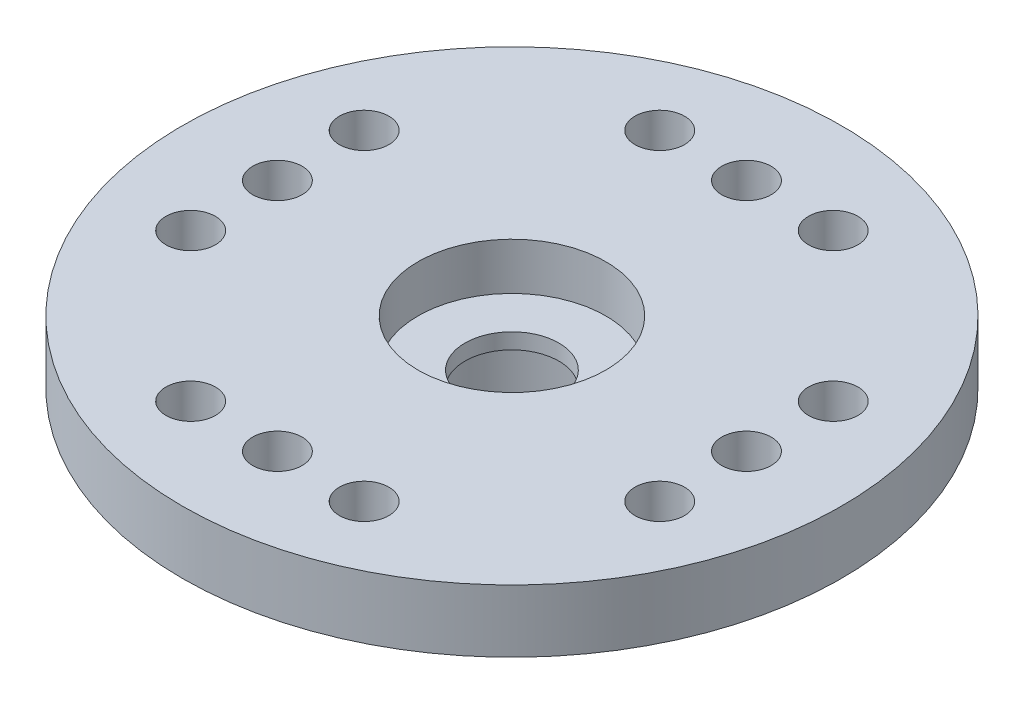
from build123d import *

# Parameters (mm, degrees)
SKETCH_1_R           = 10.525
EXTRUDE_1_DEPTH      = 2
SKETCH_2_R           = 4.1
EXTRUDE_2_DEPTH      = 3.7
SKETCH_3_R           = 2.97
CUT_EXTRUDE_1_DEPTH  = 3.7
SKETCH_4_R           = 1.5
CUT_EXTRUDE_2_DEPTH  = 2
SKETCH_5_R           = 3
CUT_EXTRUDE_3_DEPTH  = 1.5
SKETCH_6_R           = 0.79
CUT_EXTRUDE_4_DEPTH  = 2
SKETCH_7_R           = 0.79
CUT_EXTRUDE_5_DEPTH  = 2
SKETCH_8_R           = 0.79
CUT_EXTRUDE_6_DEPTH  = 2
SKETCH_9_R           = 0.79
CUT_EXTRUDE_7_DEPTH  = 2
SKETCH_10_R          = 0.79
CUT_EXTRUDE_8_DEPTH  = 2
SKETCH_11_R          = 0.79
CUT_EXTRUDE_9_DEPTH  = 2
SKETCH_12_R          = 0.79
CUT_EXTRUDE_10_DEPTH = 2
SKETCH_13_R          = 0.79
CUT_EXTRUDE_11_DEPTH = 2
SKETCH_14_R          = 0.79
CUT_EXTRUDE_12_DEPTH = 2
SKETCH_15_R          = 0.79
CUT_EXTRUDE_13_DEPTH = 2
SKETCH_16_R          = 0.79
CUT_EXTRUDE_14_DEPTH = 2
SKETCH_17_R          = 0.79
CUT_EXTRUDE_15_DEPTH = 2


with BuildPart() as part:
    # ｽｹｯﾁ1 → ﾎﾞｽ - 押し出し1 (new body)
    with BuildSketch(Plane(origin=(0, 0, 0), x_dir=(1, 0, 0), z_dir=(0, 1, 0))):
        Circle(SKETCH_1_R)
    extrude(amount=EXTRUDE_1_DEPTH)

    # ｽｹｯﾁ2 → ﾎﾞｽ - 押し出し2 (add)
    with BuildSketch(Plane(origin=(0, 0, 0), x_dir=(-1, 0, 0), z_dir=(0, -1, 0))):
        Circle(SKETCH_2_R)
    extrude(amount=EXTRUDE_2_DEPTH)

    # ｽｹｯﾁ3 → ｶｯﾄ - 押し出し1 (cut)
    with BuildSketch(Plane(origin=(0, -3.7, 0), x_dir=(-1, 0, 0), z_dir=(0, -1, 0))):
        Circle(SKETCH_3_R)
    extrude(amount=-CUT_EXTRUDE_1_DEPTH, mode=Mode.SUBTRACT)

    # ｽｹｯﾁ4 → ｶｯﾄ - 押し出し2 (cut)
    with BuildSketch(Plane(origin=(0, 2, 0), x_dir=(1, 0, 0), z_dir=(0, 1, 0))):
        Circle(SKETCH_4_R)
    extrude(amount=-CUT_EXTRUDE_2_DEPTH, mode=Mode.SUBTRACT)

    # ｽｹｯﾁ5 → ｶｯﾄ - 押し出し3 (cut)
    with BuildSketch(Plane(origin=(0, 2, 0), x_dir=(1, 0, 0), z_dir=(0, 1, 0))):
        Circle(SKETCH_5_R)
    extrude(amount=-CUT_EXTRUDE_3_DEPTH, mode=Mode.SUBTRACT)

    # ｽｹｯﾁ6 → ｶｯﾄ - 押し出し4 (cut)
    with BuildSketch(Plane(origin=(0, 2, 0), x_dir=(1, 0, 0), z_dir=(0, 1, 0))):
        with Locations((0, 7.49)):
            Circle(SKETCH_6_R)
    extrude(amount=-CUT_EXTRUDE_4_DEPTH, mode=Mode.SUBTRACT)

    # ｽｹｯﾁ7 → ｶｯﾄ - 押し出し5 (cut)
    with BuildSketch(Plane(origin=(0, 2, 0), x_dir=(1, 0, 0), z_dir=(0, 1, 0))):
        with Locations((2.77, 7.49)):
            Circle(SKETCH_7_R)
    extrude(amount=-CUT_EXTRUDE_5_DEPTH, mode=Mode.SUBTRACT)

    # ｽｹｯﾁ8 → ｶｯﾄ - 押し出し6 (cut)
    with BuildSketch(Plane(origin=(0, 2, 0), x_dir=(1, 0, 0), z_dir=(0, 1, 0))):
        with Locations((-2.77, 7.49)):
            Circle(SKETCH_8_R)
    extrude(amount=-CUT_EXTRUDE_6_DEPTH, mode=Mode.SUBTRACT)

    # ｽｹｯﾁ9 → ｶｯﾄ - 押し出し7 (cut)
    with BuildSketch(Plane(origin=(0, 2, 0), x_dir=(1, 0, 0), z_dir=(0, 1, 0))):
        with Locations((7.49, 0)):
            Circle(SKETCH_9_R)
    extrude(amount=-CUT_EXTRUDE_7_DEPTH, mode=Mode.SUBTRACT)

    # ｽｹｯﾁ10 → ｶｯﾄ - 押し出し8 (cut)
    with BuildSketch(Plane(origin=(0, 2, 0), x_dir=(1, 0, 0), z_dir=(0, 1, 0))):
        with Locations((7.49, -2.77)):
            Circle(SKETCH_10_R)
    extrude(amount=-CUT_EXTRUDE_8_DEPTH, mode=Mode.SUBTRACT)

    # ｽｹｯﾁ11 → ｶｯﾄ - 押し出し9 (cut)
    with BuildSketch(Plane(origin=(0, 2, 0), x_dir=(1, 0, 0), z_dir=(0, 1, 0))):
        with Locations((7.49, 2.77)):
            Circle(SKETCH_11_R)
    extrude(amount=-CUT_EXTRUDE_9_DEPTH, mode=Mode.SUBTRACT)

    # ｽｹｯﾁ12 → ｶｯﾄ - 押し出し10 (cut)
    with BuildSketch(Plane(origin=(0, 2, 0), x_dir=(1, 0, 0), z_dir=(0, 1, 0))):
        with Locations((0, -7.49)):
            Circle(SKETCH_12_R)
    extrude(amount=-CUT_EXTRUDE_10_DEPTH, mode=Mode.SUBTRACT)

    # ｽｹｯﾁ13 → ｶｯﾄ - 押し出し11 (cut)
    with BuildSketch(Plane(origin=(0, 2, 0), x_dir=(1, 0, 0), z_dir=(0, 1, 0))):
        with Locations((2.77, -7.49)):
            Circle(SKETCH_13_R)
    extrude(amount=-CUT_EXTRUDE_11_DEPTH, mode=Mode.SUBTRACT)

    # ｽｹｯﾁ14 → ｶｯﾄ - 押し出し12 (cut)
    with BuildSketch(Plane(origin=(0, 2, 0), x_dir=(1, 0, 0), z_dir=(0, 1, 0))):
        with Locations((-2.77, -7.49)):
            Circle(SKETCH_14_R)
    extrude(amount=-CUT_EXTRUDE_12_DEPTH, mode=Mode.SUBTRACT)

    # ｽｹｯﾁ15 → ｶｯﾄ - 押し出し13 (cut)
    with BuildSketch(Plane(origin=(0, 2, 0), x_dir=(1, 0, 0), z_dir=(0, 1, 0))):
        with Locations((-7.49, 0)):
            Circle(SKETCH_15_R)
    extrude(amount=-CUT_EXTRUDE_13_DEPTH, mode=Mode.SUBTRACT)

    # ｽｹｯﾁ16 → ｶｯﾄ - 押し出し14 (cut)
    with BuildSketch(Plane(origin=(0, 2, 0), x_dir=(1, 0, 0), z_dir=(0, 1, 0))):
        with Locations((-7.49, 2.77)):
            Circle(SKETCH_16_R)
    extrude(amount=-CUT_EXTRUDE_14_DEPTH, mode=Mode.SUBTRACT)

    # ｽｹｯﾁ17 → ｶｯﾄ - 押し出し15 (cut)
    with BuildSketch(Plane(origin=(0, 2, 0), x_dir=(1, 0, 0), z_dir=(0, 1, 0))):
        with Locations((-7.49, -2.77)):
            Circle(SKETCH_17_R)
    extrude(amount=-CUT_EXTRUDE_15_DEPTH, mode=Mode.SUBTRACT)


solid = part.part
